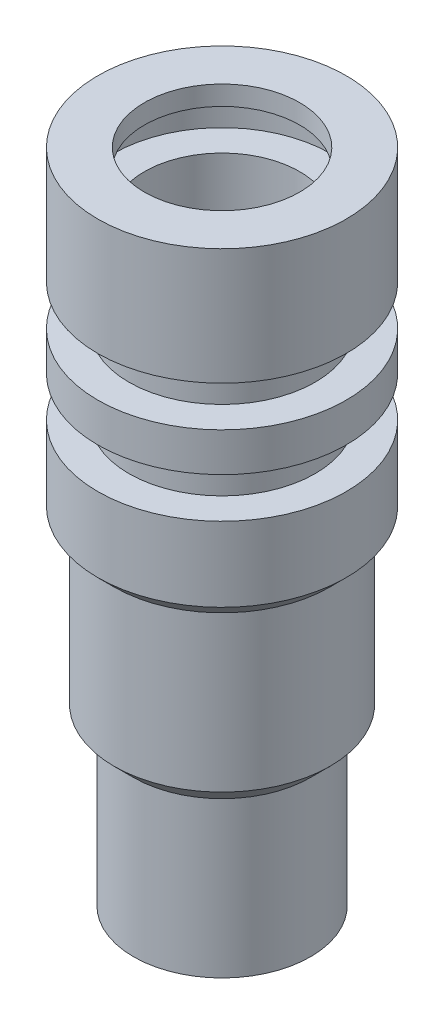
from build123d import *


with BuildPart() as part:
    # Sketch1 → Revolve1 (revolve)
    with BuildSketch(Plane.XY):
        Polygon((-6.35, 0), (-10.16, 0), (-10.16, -9.525), (-7.62, -9.525), (-7.62, -12.827), (-10.16, -12.827), (-10.16, -16.002), (-7.62, -16.002), (-7.62, -19.304), (-10.16, -19.304), (-10.16, -25.4), (-8.8265, -26.7335), (-8.8265, -39.4335), (-7.239, -41.021), (-7.239, -53.721), (-6.35, -53.721), (-6.35, -4.8895), (-8.89, -4.8895), (-8.89, -1.5875), (-6.35, -1.5875), align=None)
    revolve(axis=Axis((0, 0, 0), (0, -1, 0)))


solid = part.part
